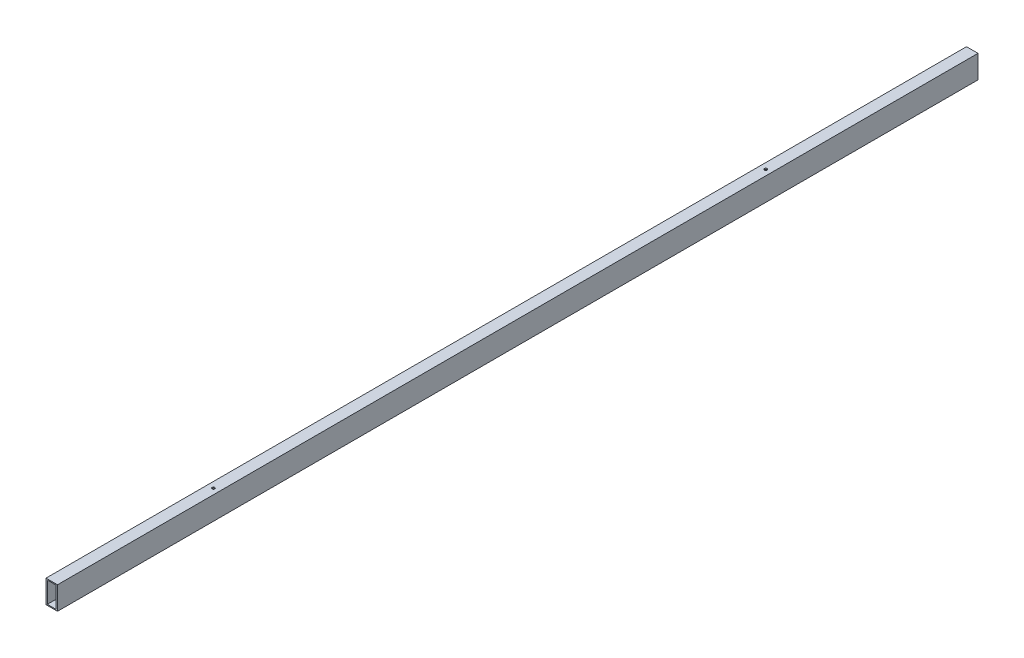
from build123d import *

# Parameters (mm, degrees)
ESQUISSE1_W                  = 25
ESQUISSE1_H                  = 50
ESQUISSE1_W_2                = 19.086637974
ESQUISSE1_H_2                = 45.621468926
BOSS_EXTRU_1_DEPTH           = 2000
ESQUISSE2_R                  = 3
ENL_V_MAT_EXTRU_1_DEPTH      = 1
ENL_V_MAT_EXTRU_1_DEPTH_BACK = 51
ESQUISSE3_R                  = 3
ENL_V_MAT_EXTRU_2_DEPTH      = 1
ENL_V_MAT_EXTRU_2_DEPTH_BACK = 51


with BuildPart() as part:
    # Esquisse1 → Boss.-Extru.1 (new body)
    with BuildSketch(Plane.XY):
        Rectangle(ESQUISSE1_W, ESQUISSE1_H)
        Rectangle(ESQUISSE1_W_2, ESQUISSE1_H_2, mode=Mode.SUBTRACT)
    extrude(amount=BOSS_EXTRU_1_DEPTH)

    # Esquisse2 → Enlèv. mat.-Extru.1 (cut, two sides)
    with BuildSketch(Plane(origin=(0, 25, 0), x_dir=(1, 0, 0), z_dir=(0, 1, 0))) as enl_v_mat_extru_1_sk:
        with Locations((0.185438708, -1648.872663575)):
            Circle(ESQUISSE2_R)
    extrude(amount=ENL_V_MAT_EXTRU_1_DEPTH, mode=Mode.SUBTRACT)
    extrude(enl_v_mat_extru_1_sk.sketch, amount=-ENL_V_MAT_EXTRU_1_DEPTH_BACK, mode=Mode.SUBTRACT)

    # Esquisse3 → Enlèv. mat.-Extru.2 (cut, two sides)
    with BuildSketch(Plane(origin=(0, 25, 0), x_dir=(1, 0, 0), z_dir=(0, 1, 0))) as enl_v_mat_extru_2_sk:
        with Locations((0.185438708, -448.872663575)):
            Circle(ESQUISSE3_R)
    extrude(amount=ENL_V_MAT_EXTRU_2_DEPTH, mode=Mode.SUBTRACT)
    extrude(enl_v_mat_extru_2_sk.sketch, amount=-ENL_V_MAT_EXTRU_2_DEPTH_BACK, mode=Mode.SUBTRACT)


solid = part.part
